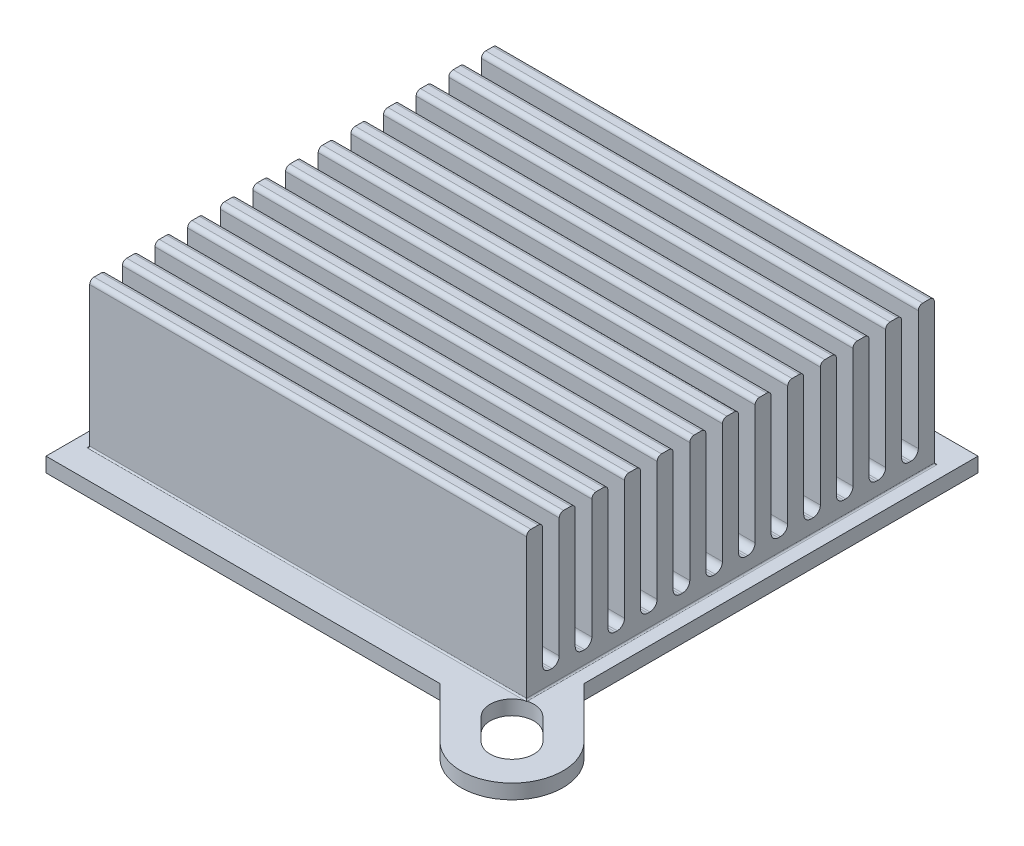
from build123d import *

# Parameters (mm, degrees)
SZKIC1_W                    = 32
SZKIC1_H                    = 32
DODANIE_WYCI_GNI_CIE2_DEPTH = 1
SZKIC3_W                    = 30
SZKIC3_H                    = 28
DODANIE_WYCI_GNI_CIE3_DEPTH = 1
SZKIC2_W                    = 30
SZKIC2_H                    = 1.1
DODANIE_WYCI_GNI_CIE4_DEPTH = 10
ZAOKR_GLENIE1_R             = 0.1
ZAOKR_GLENIE3_R             = 0.5
ZAOKR_GLENIE4_R             = 0.3
WYTNIJ_WYCI_GNI_CIE1_DEPTH  = 2


with BuildPart() as part:
    # Szkic1 → Dodanie-wyciągnięcie2 (new body)
    with BuildSketch(Plane(origin=(0, 0, 0), x_dir=(1, 0, 0), z_dir=(0, 1, 0))):
        Rectangle(SZKIC1_W, SZKIC1_H)
        with BuildLine():
            Line((-14.495689014, 19.445436483), (19.445436483, -14.495689014))
            ThreePointArc((19.445436483, -14.495689014), (19.445436483, -19.445436483), (14.495689014, -19.445436483))
            Line((14.495689014, -19.445436483), (-19.445436483, 14.495689014))
            ThreePointArc((-19.445436483, 14.495689014), (-19.445436483, 19.445436483), (-14.495689014, 19.445436483))
        make_face()
    extrude(amount=DODANIE_WYCI_GNI_CIE2_DEPTH)

    # Szkic3 → Dodanie-wyciągnięcie3 (add)
    with BuildSketch(Plane(origin=(0, 1, 0), x_dir=(1, 0, 0), z_dir=(0, 1, 0))):
        Rectangle(SZKIC3_W, SZKIC3_H)
    extrude(amount=DODANIE_WYCI_GNI_CIE3_DEPTH)

    # Szkic2 → Dodanie-wyciągnięcie4 (add)
    with BuildSketch(Plane(origin=(0, 1, 0), x_dir=(1, 0, 0), z_dir=(0, 1, 0))):
        with Locations((0, 13.45)):
            Rectangle(SZKIC2_W, SZKIC2_H)
        with Locations((0, 11.208333333)):
            Rectangle(SZKIC2_W, SZKIC2_H)
        with Locations((0, 8.966666667)):
            Rectangle(SZKIC2_W, SZKIC2_H)
        with Locations((0, 6.725)):
            Rectangle(SZKIC2_W, SZKIC2_H)
        with Locations((0, 4.483333333)):
            Rectangle(SZKIC2_W, SZKIC2_H)
        with Locations((0, 2.241666667)):
            Rectangle(SZKIC2_W, SZKIC2_H)
        Rectangle(SZKIC2_W, SZKIC2_H)
        with Locations((0, -2.241666667)):
            Rectangle(SZKIC2_W, SZKIC2_H)
        with Locations((0, -4.483333333)):
            Rectangle(SZKIC2_W, SZKIC2_H)
        with Locations((0, -6.725)):
            Rectangle(SZKIC2_W, SZKIC2_H)
        with Locations((0, -8.966666667)):
            Rectangle(SZKIC2_W, SZKIC2_H)
        with Locations((0, -11.208333333)):
            Rectangle(SZKIC2_W, SZKIC2_H)
        with Locations((0, -13.45)):
            Rectangle(SZKIC2_W, SZKIC2_H)
    extrude(amount=DODANIE_WYCI_GNI_CIE4_DEPTH)

    # Zaokrąglenie1
    zaokr_glenie1_edges = [part.edges().sort_by_distance(p)[0] for p in [
        (-15, 1, 0),
        (0, 1, 14),
        (15, 1, 0),
        (0, 1, -14),
    ]]
    fillet(zaokr_glenie1_edges, radius=ZAOKR_GLENIE1_R)

    # Zaokrąglenie3
    zaokr_glenie3_edges = [part.edges().sort_by_distance(p)[0] for p in [
        (0, 2, -6.175),
        (0, 2, -7.275),
        (0, 2, -3.933333333),
        (0, 2, -5.033333333),
        (0, 2, -1.691666667),
        (0, 2, -2.791666667),
        (0, 2, 0.55),
        (0, 2, -0.55),
        (0, 2, 2.791666667),
        (0, 2, 1.691666667),
        (0, 2, 5.033333333),
        (0, 2, 3.933333333),
        (0, 2, 7.275),
        (0, 2, 6.175),
        (0, 2, 9.516666667),
        (0, 2, 8.416666667),
        (0, 2, 11.758333333),
        (0, 2, 10.658333333),
        (0, 2, 12.9),
        (0, 2, -12.9),
        (0, 2, -10.658333333),
        (0, 2, -11.758333333),
        (0, 2, -8.416666667),
        (0, 2, -9.516666667),
    ]]
    fillet(zaokr_glenie3_edges, radius=ZAOKR_GLENIE3_R)

    # Zaokrąglenie4
    zaokr_glenie4_edges = [part.edges().sort_by_distance(p)[0] for p in [
        (0, 11, -6.175),
        (0, 11, -7.275),
        (0, 11, -3.933333333),
        (0, 11, -5.033333333),
        (0, 11, -1.691666667),
        (0, 11, -2.791666667),
        (0, 11, 0.55),
        (0, 11, -0.55),
        (0, 11, 2.791666667),
        (0, 11, 1.691666667),
        (0, 11, 5.033333333),
        (0, 11, 3.933333333),
        (0, 11, 7.275),
        (0, 11, 6.175),
        (0, 11, 9.516666667),
        (0, 11, 8.416666667),
        (0, 11, 11.758333333),
        (0, 11, 10.658333333),
        (0, 11, 14),
        (0, 11, 12.9),
        (0, 11, -12.9),
        (0, 11, -14),
        (0, 11, -10.658333333),
        (0, 11, -11.758333333),
        (0, 11, -8.416666667),
        (0, 11, -9.516666667),
    ]]
    fillet(zaokr_glenie4_edges, radius=ZAOKR_GLENIE4_R)

    # Szkic4 → Wytnij-wyciągnięcie1 (cut, through all)
    with BuildSketch(Plane(origin=(0, 1, 0), x_dir=(1, 0, 0), z_dir=(0, 1, 0))):
        with BuildLine():
            Line((-15.909902577, 18.03122292), (-14.439120472, 16.560440815))
            ThreePointArc((-14.439120472, 16.560440815), (-14.439120472, 14.439120472), (-16.560440815, 14.439120472))
            Line((-16.560440815, 14.439120472), (-18.03122292, 15.909902577))
            ThreePointArc((-18.03122292, 15.909902577), (-18.03122292, 18.03122292), (-15.909902577, 18.03122292))
        make_face()
        with BuildLine():
            Line((15.909902577, -18.03122292), (14.439120472, -16.560440815))
            ThreePointArc((14.439120472, -16.560440815), (14.439120472, -14.439120472), (16.560440815, -14.439120472))
            Line((16.560440815, -14.439120472), (18.03122292, -15.909902577))
            ThreePointArc((18.03122292, -15.909902577), (18.03122292, -18.03122292), (15.909902577, -18.03122292))
        make_face()
    extrude(amount=-WYTNIJ_WYCI_GNI_CIE1_DEPTH, mode=Mode.SUBTRACT)


solid = part.part
